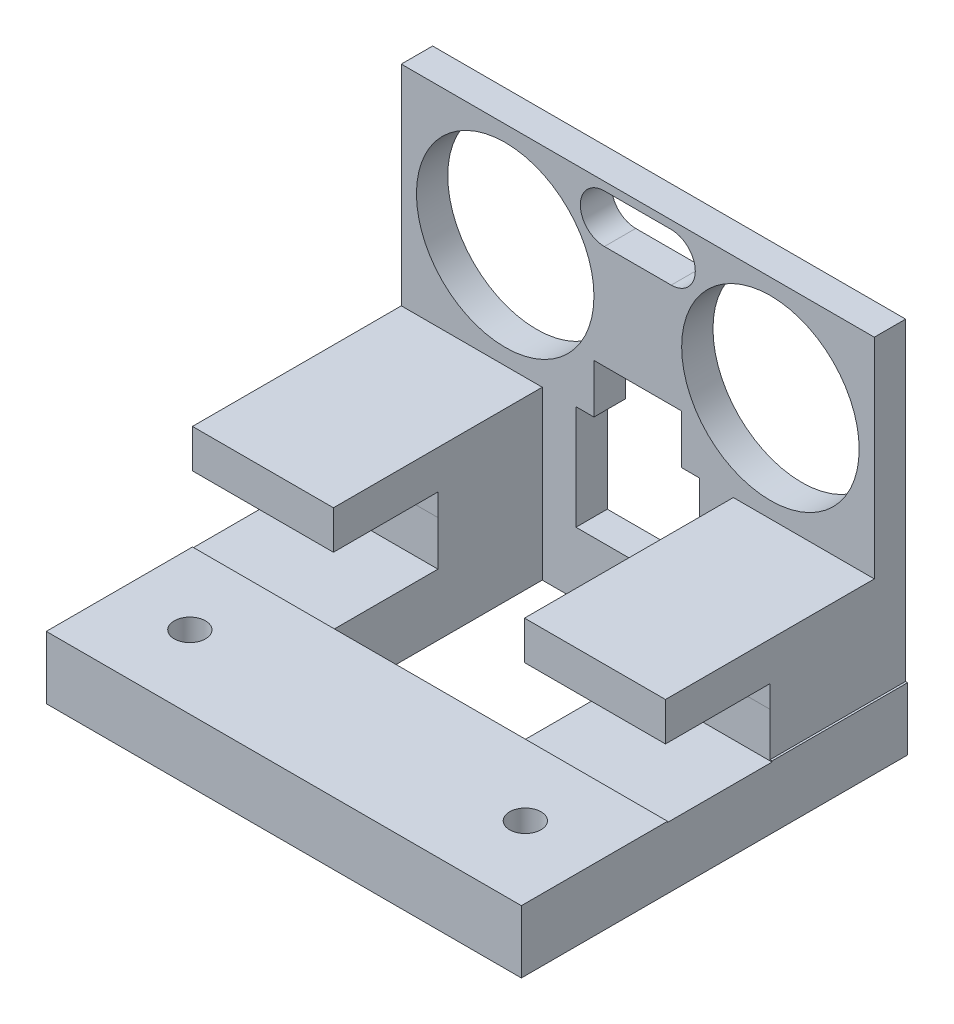
from build123d import *

# Parameters (mm, degrees)
SKETCH1_W            = 45.3
SKETCH1_H            = 20.05
BOSS_EXTRUDE1_DEPTH  = 3
SKETCH2_R            = 8.5
CUT_EXTRUDE1_DEPTH   = 4
SKETCH3_W            = 8.4
SKETCH3_H            = 4.7
CUT_EXTRUDE2_DEPTH   = 1
SKETCH10_W           = 16.728431373
SKETCH10_H           = 3
BOSS_EXTRUDE8_DEPTH  = 10
SKETCH11_W           = 13.5
SKETCH11_H           = 10
BOSS_EXTRUDE9_DEPTH  = 20
SKETCH12_W           = 13.5
SKETCH12_H           = 2.12
CUT_EXTRUDE3_DEPTH   = 10
SKETCH13_W           = 13.5
SKETCH13_H           = 4
BOSS_EXTRUDE10_DEPTH = 6
SKETCH14_W           = 4
SKETCH14_H           = 3
BOSS_EXTRUDE11_DEPTH = 32
SKETCH15_W           = 32
SKETCH15_H           = 4
BOSS_EXTRUDE12_DEPTH = 3
SKETCH16_W           = 45.5
SKETCH16_H           = 6
BOSS_EXTRUDE13_DEPTH = 33
SKETCH17_W           = 18.3
SKETCH17_H           = 20
CUT_EXTRUDE4_DEPTH   = 7
SKETCH18_R           = 1.5
CUT_EXTRUDE5_DEPTH   = 7
SKETCH20_W           = 10.008836356
SKETCH20_H           = 4.284437553
CUT_EXTRUDE6_DEPTH   = 46.5
SKETCH21_W           = 8.4
SKETCH21_H           = 4.7
CUT_EXTRUDE7_DEPTH   = 3


with BuildPart() as part:
    # Sketch1 → Boss-Extrude1 (new body)
    with BuildSketch(Plane.XY):
        with Locations((22.65, 10.025)):
            Rectangle(SKETCH1_W, SKETCH1_H)
    extrude(amount=BOSS_EXTRUDE1_DEPTH)

    # Sketch2 → Cut-Extrude1 (cut, through all)
    with BuildSketch(Plane.XY.offset(3)):
        with Locations((9.95, 10.025)):
            Circle(SKETCH2_R)
        with Locations((35.35, 10.025)):
            Circle(SKETCH2_R)
        with BuildLine():
            Line((19.45, 19.255641391), (25.85, 19.255641391))
            ThreePointArc((25.85, 19.255641391), (28.155641391, 16.95), (25.85, 14.644358609))
            Line((25.85, 14.644358609), (19.45, 14.644358609))
            ThreePointArc((19.45, 14.644358609), (17.144358609, 16.95), (19.45, 19.255641391))
        make_face()
    extrude(amount=-CUT_EXTRUDE1_DEPTH, mode=Mode.SUBTRACT)

    # Sketch3 → Cut-Extrude2 (cut)
    with BuildSketch(Plane.XY.offset(3)):
        with Locations((22.65, 2.35)):
            Rectangle(SKETCH3_W, SKETCH3_H)
    extrude(amount=-CUT_EXTRUDE2_DEPTH, mode=Mode.SUBTRACT)

    # Sketch10 → Boss-Extrude8 (add)
    with BuildSketch(Plane.XZ):
        with Locations((8.364215686, 1.5)):
            Rectangle(SKETCH10_W, SKETCH10_H)
        with Locations((36.935784314, 1.5)):
            Rectangle(SKETCH10_W, SKETCH10_H)
    extrude(amount=BOSS_EXTRUDE8_DEPTH)

    # Sketch11 → Boss-Extrude9 (add)
    with BuildSketch(Plane.XY.offset(3)):
        with Locations((6.75, -5)):
            Rectangle(SKETCH11_W, SKETCH11_H)
        with Locations((38.55, -5)):
            Rectangle(SKETCH11_W, SKETCH11_H)
    extrude(amount=BOSS_EXTRUDE9_DEPTH)

    # Sketch12 → Cut-Extrude3 (cut)
    with BuildSketch(Plane.XY.offset(23)):
        with Locations((6.75, -4.750002431)):
            Rectangle(SKETCH12_W, SKETCH12_H)
        with Locations((38.55, -4.750002431)):
            Rectangle(SKETCH12_W, SKETCH12_H)
    extrude(amount=-CUT_EXTRUDE3_DEPTH, mode=Mode.SUBTRACT)

    # Sketch13 → Boss-Extrude10 (add)
    with BuildSketch(Plane.XZ.offset(10)):
        with Locations((6.75, 2)):
            Rectangle(SKETCH13_W, SKETCH13_H)
    extrude(amount=BOSS_EXTRUDE10_DEPTH)

    # Sketch14 → Boss-Extrude11 (add)
    with BuildSketch(Plane(origin=(13.5, 0, 0), x_dir=(0, 0, -1), z_dir=(1, 0, 0))):
        with Locations((-2, -14.5)):
            Rectangle(SKETCH14_W, SKETCH14_H)
    extrude(amount=BOSS_EXTRUDE11_DEPTH)

    # Sketch15 → Boss-Extrude12 (add)
    with BuildSketch(Plane(origin=(0, -13, 0), x_dir=(1, 0, 0), z_dir=(0, 1, 0))):
        with Locations((29.5, -2)):
            Rectangle(SKETCH15_W, SKETCH15_H)
    extrude(amount=BOSS_EXTRUDE12_DEPTH)

    # Sketch16 → Boss-Extrude13 (add)
    with BuildSketch(Plane.XY.offset(4)):
        with Locations((22.75, -13)):
            Rectangle(SKETCH16_W, SKETCH16_H)
    extrude(amount=BOSS_EXTRUDE13_DEPTH)

    # Sketch17 → Cut-Extrude4 (cut, through all)
    with BuildSketch(Plane(origin=(0, -10, 0), x_dir=(1, 0, 0), z_dir=(0, 1, 0))):
        with Locations((22.65, -13)):
            Rectangle(SKETCH17_W, SKETCH17_H)
    extrude(amount=-CUT_EXTRUDE4_DEPTH, mode=Mode.SUBTRACT)

    # Sketch18 → Cut-Extrude5 (cut, through all)
    with BuildSketch(Plane(origin=(0, -10, 0), x_dir=(1, 0, 0), z_dir=(0, 1, 0))):
        with Locations((6.75, -30)):
            Circle(SKETCH18_R)
        with Locations((38.648372532, -29.772154482)):
            Circle(SKETCH18_R)
    extrude(amount=-CUT_EXTRUDE5_DEPTH, mode=Mode.SUBTRACT)

    # Sketch20 → Cut-Extrude6 (cut, through all)
    with BuildSketch(Plane.ZY):
        with Locations((17.995581822, -7.952221208)):
            Rectangle(SKETCH20_W, SKETCH20_H)
    extrude(amount=-CUT_EXTRUDE6_DEPTH, mode=Mode.SUBTRACT)

    # Sketch21 → Cut-Extrude7 (cut, through all)
    with BuildSketch(Plane.XY.offset(2)):
        with Locations((22.65, 2.35)):
            Rectangle(SKETCH21_W, SKETCH21_H)
    extrude(amount=-CUT_EXTRUDE7_DEPTH, mode=Mode.SUBTRACT)


solid = part.part
